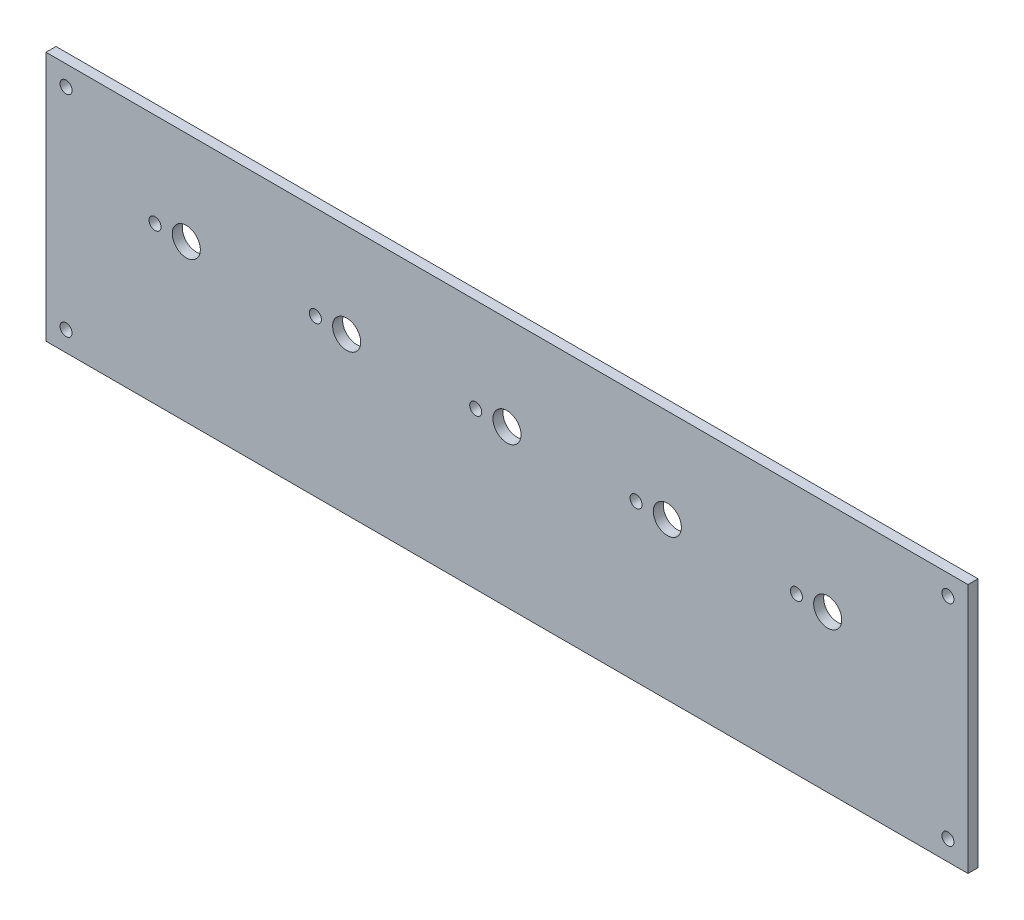
from build123d import *

# Parameters (mm, degrees)
SKETCH1_W           = 230
SKETCH1_H           = 62.43
BOSS_EXTRUDE1_DEPTH = 2.5
SKETCH2_R           = 1.5
CUT_EXTRUDE1_DEPTH  = 10
SKETCH3_R           = 3.5
SKETCH3_R_2         = 1.5
CUT_EXTRUDE2_DEPTH  = 2.5


with BuildPart() as part:
    # Sketch1 → Boss-Extrude1 (new body)
    with BuildSketch(Plane.XY):
        with Locations((115, 31.215)):
            Rectangle(SKETCH1_W, SKETCH1_H)
    extrude(amount=BOSS_EXTRUDE1_DEPTH)

    # Sketch2 → Cut-Extrude1 (cut)
    with BuildSketch(Plane.XY.offset(2.5)):
        with Locations((5, 57.43)):
            Circle(SKETCH2_R)
        with Locations((5, 5)):
            Circle(SKETCH2_R)
        with Locations((225, 5)):
            Circle(SKETCH2_R)
        with Locations((225, 57.43)):
            Circle(SKETCH2_R)
    extrude(amount=-CUT_EXTRUDE1_DEPTH, mode=Mode.SUBTRACT)

    # Sketch3 → Cut-Extrude2 (cut)
    with BuildSketch(Plane.XY.offset(2.5)):
        with Locations((115, 39.01875)):
            Circle(SKETCH3_R)
        with Locations((107.2, 39.01875)):
            Circle(SKETCH3_R_2)
        with Locations((155, 39.01875)):
            Circle(SKETCH3_R)
        with Locations((147.2, 39.01875)):
            Circle(SKETCH3_R_2)
        with Locations((195, 39.01875)):
            Circle(SKETCH3_R)
        with Locations((187.2, 39.01875)):
            Circle(SKETCH3_R_2)
        with Locations((67.2, 39.01875)):
            Circle(SKETCH3_R_2)
        with Locations((75, 39.01875)):
            Circle(SKETCH3_R)
        with Locations((27.2, 39.01875)):
            Circle(SKETCH3_R_2)
        with Locations((35, 39.01875)):
            Circle(SKETCH3_R)
    extrude(amount=-CUT_EXTRUDE2_DEPTH, mode=Mode.SUBTRACT)


solid = part.part
